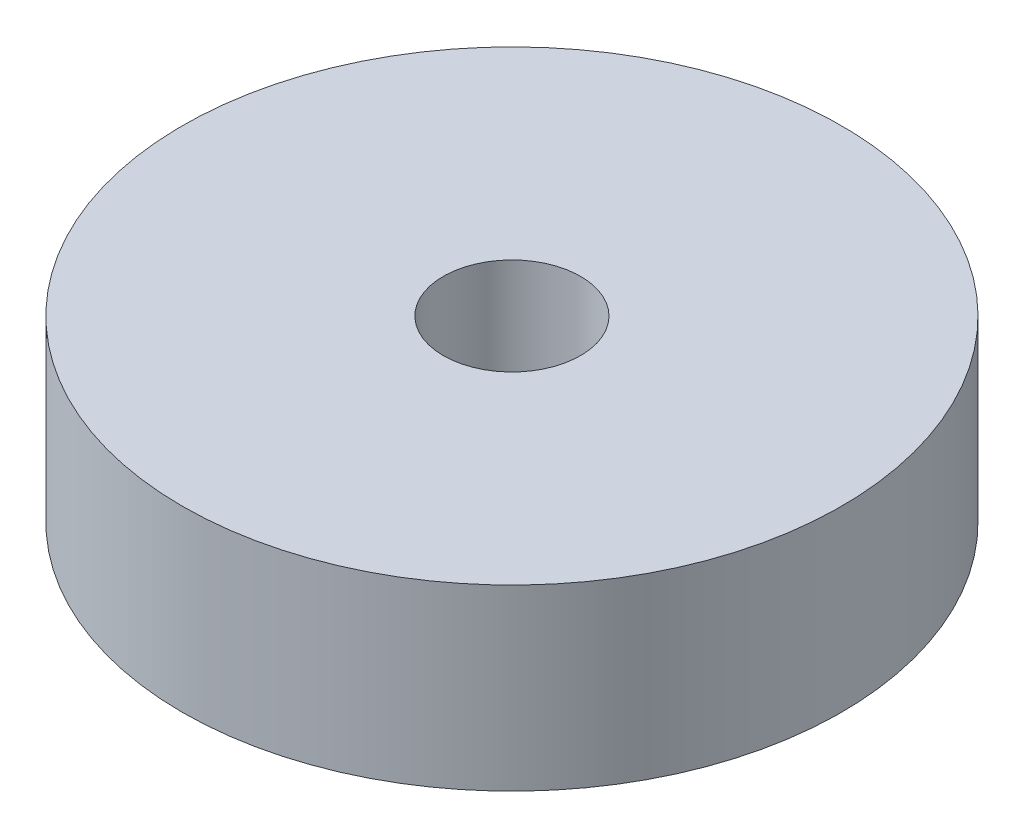
from build123d import *

# Parameters (mm, degrees)
SKETCH1_R           = 24
BOSS_EXTRUDE1_DEPTH = 13
SKETCH2_R           = 5
CUT_EXTRUDE1_DEPTH  = 10
SKETCH3_R           = 1.5
CUT_EXTRUDE2_DEPTH  = 8


with BuildPart() as part:
    # Sketch1 → Boss-Extrude1 (new body)
    with BuildSketch(Plane(origin=(0, 0, 0), x_dir=(1, 0, 0), z_dir=(0, 1, 0))):
        Circle(SKETCH1_R)
    extrude(amount=BOSS_EXTRUDE1_DEPTH)

    # Sketch2 → Cut-Extrude1 (cut)
    with BuildSketch(Plane(origin=(0, 13, 0), x_dir=(1, 0, 0), z_dir=(0, 1, 0))):
        Circle(SKETCH2_R)
    extrude(amount=-CUT_EXTRUDE1_DEPTH, mode=Mode.SUBTRACT)

    # Sketch3 → Cut-Extrude2 (cut)
    with BuildSketch(Plane(origin=(0, 0, 0), x_dir=(-1, 0, 0), z_dir=(0, -1, 0))):
        with BuildLine():
            ThreePointArc((11, -9.5), (9.939339828, -9.939339828), (9.5, -11))
            Line((9.5, -11), (11, -11))
            Line((11, -11), (11, -9.5))
        make_face()
        with BuildLine():
            Line((11, -11), (9.5, -11))
            ThreePointArc((9.5, -11), (11, -12.5), (12.5, -11))
            ThreePointArc((12.5, -11), (12.060660172, -9.939339828), (11, -9.5))
            Line((11, -9.5), (11, -11))
        make_face()
        with BuildLine():
            ThreePointArc((-11, -9.5), (-12.060660172, -12.060660172), (-9.5, -11))
            Line((-9.5, -11), (-11, -11))
            Line((-11, -11), (-11, -9.5))
        make_face()
        with BuildLine():
            Line((-11, -11), (-9.5, -11))
            ThreePointArc((-9.5, -11), (-9.939339828, -9.939339828), (-11, -9.5))
            Line((-11, -9.5), (-11, -11))
        make_face()
        with Locations((11, 11)):
            Circle(SKETCH3_R)
        with Locations((-11, 11)):
            Circle(SKETCH3_R)
    extrude(amount=-CUT_EXTRUDE2_DEPTH, mode=Mode.SUBTRACT)


solid = part.part
